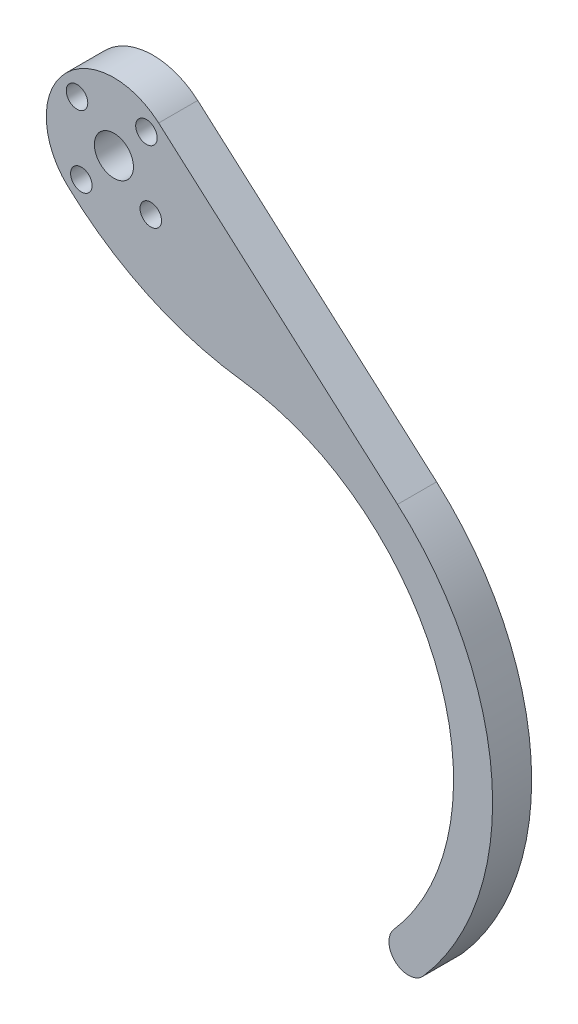
from build123d import *

# Parameters (mm, degrees)
BOSS_EXTRUDE1_DEPTH = 6.35
SKETCH2_R           = 3.175
SKETCH2_R_2         = 1.75
CUT_EXTRUDE1_DEPTH  = 7.35


with BuildPart() as part:
    # Sketch1 → Boss-Extrude1 (new body)
    with BuildSketch(Plane.XY):
        with BuildLine():
            Line((-8.595455009, 68.571709933), (30.25643609, 34.276325287))
            ThreePointArc((30.25643609, 34.276325287), (45.624300947, 2.956613457), (34.427247837, -30.084597493))
            ThreePointArc((34.427247837, -30.084597493), (29.947258578, -30.386170434), (29.645685638, -25.906181175))
            ThreePointArc((29.645685638, -25.906181175), (36.792348261, 14.011424249), (4.903675305, 39.063421106))
            ThreePointArc((4.903675305, 39.063421106), (-10.270602503, 43.44261231), (-23.366607565, 52.270447493))
            ThreePointArc((-23.366607565, 52.270447493), (-24.02632087, 67.711201194), (-8.595455009, 68.571709933))
        make_face()
    extrude(amount=BOSS_EXTRUDE1_DEPTH)

    # Sketch2 → Cut-Extrude1 (cut, through all)
    with BuildSketch(Plane.XY.offset(6.35)):
        with Locations((-15.875, 60.325)):
            Circle(SKETCH2_R)
        with Locations((-10.580785461, 66.322607224)):
            Circle(SKETCH2_R_2)
        with Locations((-9.877392776, 55.030785461)):
            Circle(SKETCH2_R_2)
        with Locations((-21.169214539, 54.327392776)):
            Circle(SKETCH2_R_2)
        with Locations((-21.872607224, 65.619214539)):
            Circle(SKETCH2_R_2)
    extrude(amount=-CUT_EXTRUDE1_DEPTH, mode=Mode.SUBTRACT)


solid = part.part
